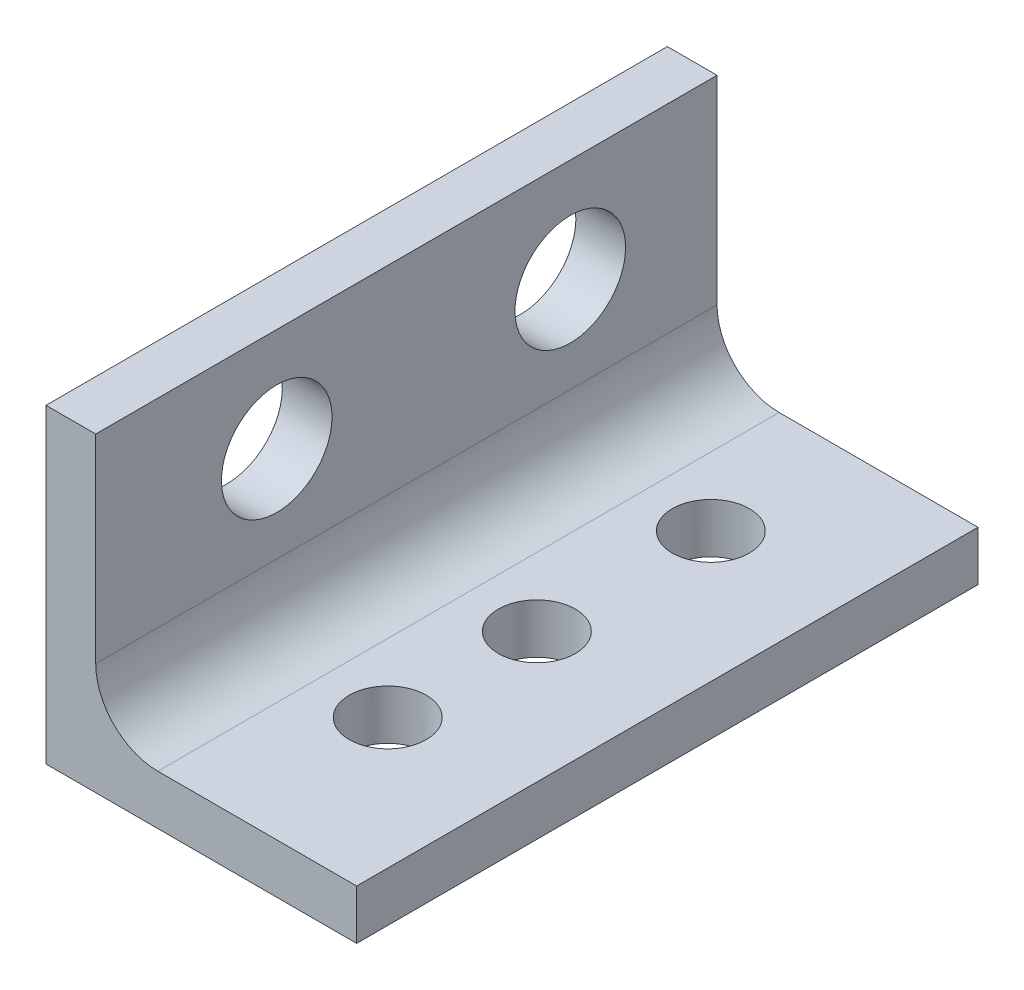
from build123d import *

# Parameters (mm, degrees)
BOSS_EXTRUDE1_DEPTH = 12.7
SKETCH3_R           = 0.7874
CUT_EXTRUDE1_DEPTH  = 2.54
FILLET1_R           = 1.27
CUT_EXTRUDE2_REACH  = 3.016
SKETCH4_R           = 1.1303


with BuildPart() as part:
    # Sketch1 → Boss-Extrude1 (new body)
    with BuildSketch(Plane.XY):
        Polygon((-6.35, 6.35), (-6.35, 0), (0, 0), (0, 1.016), (-5.334, 1.016), (-5.334, 6.35), align=None)
    extrude(amount=BOSS_EXTRUDE1_DEPTH)

    # Sketch3 → Cut-Extrude1 (cut)
    with BuildSketch(Plane(origin=(0, 1.016, 0), x_dir=(1, 0, 0), z_dir=(0, 1, 0))):
        with Locations((-2.667, -6.35)):
            Circle(SKETCH3_R)
        with Locations((-2.667, -9.398)):
            Circle(SKETCH3_R)
        with Locations((-2.667, -2.794)):
            Circle(SKETCH3_R)
    extrude(amount=-CUT_EXTRUDE1_DEPTH, mode=Mode.SUBTRACT)

    # Fillet1
    fillet1_edges = [part.edges().sort_by_distance(p)[0] for p in [
        (-5.334, 1.016, 6.35),
    ]]
    fillet(fillet1_edges, radius=FILLET1_R)

    # Sketch4 → Cut-Extrude2 (cut, up to next)
    with BuildSketch(Plane(origin=(-5.334, 0, 0), x_dir=(0, 0, -1), z_dir=(1, 0, 0)), mode=Mode.PRIVATE) as cut_extrude2_sk1:
        with Locations((-9, 4.24)):
            Circle(SKETCH4_R)
    cut_extrude2_tool1 = extrude(cut_extrude2_sk1.sketch, amount=-CUT_EXTRUDE2_REACH, mode=Mode.PRIVATE) & part.part
    add(cut_extrude2_tool1.solids().sort_by_distance((-5.334, 4.24, 9))[0], mode=Mode.SUBTRACT)
    # Sketch4 → Cut-Extrude2 (cut, up to next)
    with BuildSketch(Plane(origin=(-5.334, 0, 0), x_dir=(0, 0, -1), z_dir=(1, 0, 0)), mode=Mode.PRIVATE) as cut_extrude2_sk2:
        with Locations((-3, 4.24)):
            Circle(SKETCH4_R)
    cut_extrude2_tool2 = extrude(cut_extrude2_sk2.sketch, amount=-CUT_EXTRUDE2_REACH, mode=Mode.PRIVATE) & part.part
    add(cut_extrude2_tool2.solids().sort_by_distance((-5.334, 4.24, 3))[0], mode=Mode.SUBTRACT)


solid = part.part
